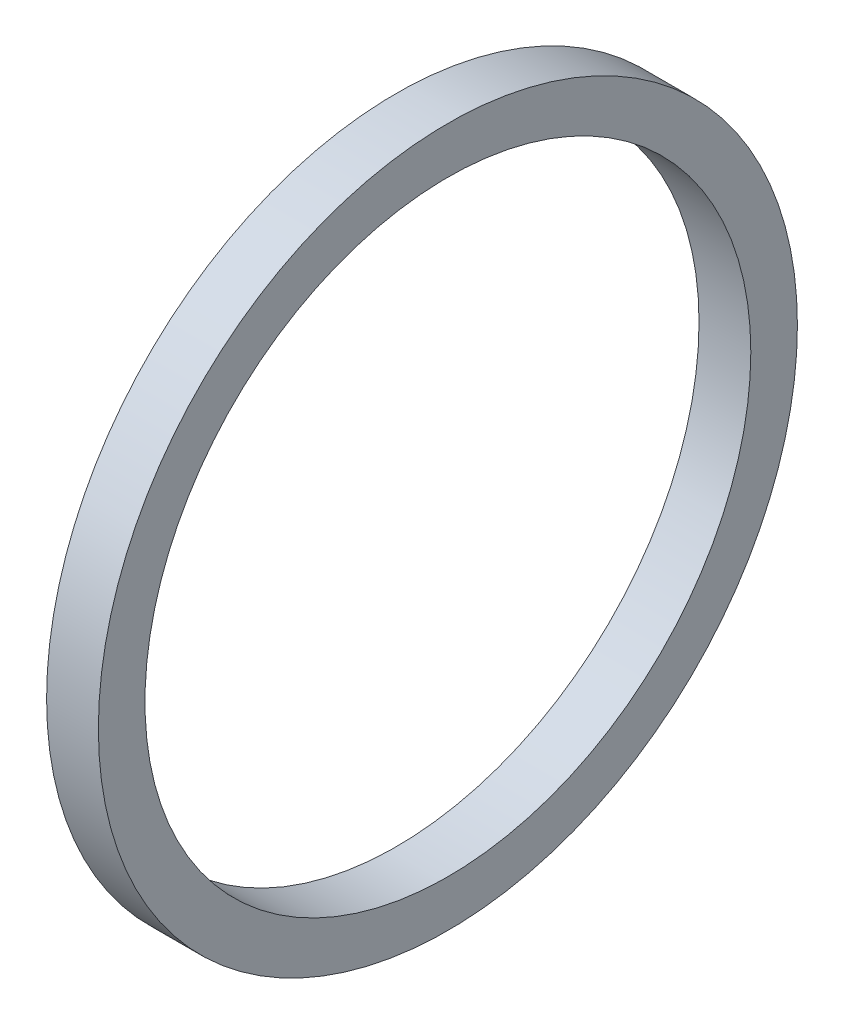
from build123d import *

# Parameters (mm, degrees)
SKETCH1_R       = 1.7145
SKETCH1_R_2     = 1.4859
SNAP_RING_DEPTH = 0.254


with BuildPart() as part:
    # Sketch1 → Snap ring (new body)
    with BuildSketch(Plane(origin=(0, 0, 0), x_dir=(0, 0, -1), z_dir=(1, 0, 0))):
        with Locations((-1.477619406, 0.156651527)):
            Circle(SKETCH1_R)
        with Locations((-1.477619406, 0.156651527)):
            Circle(SKETCH1_R_2, mode=Mode.SUBTRACT)
    extrude(amount=SNAP_RING_DEPTH)


solid = part.part
